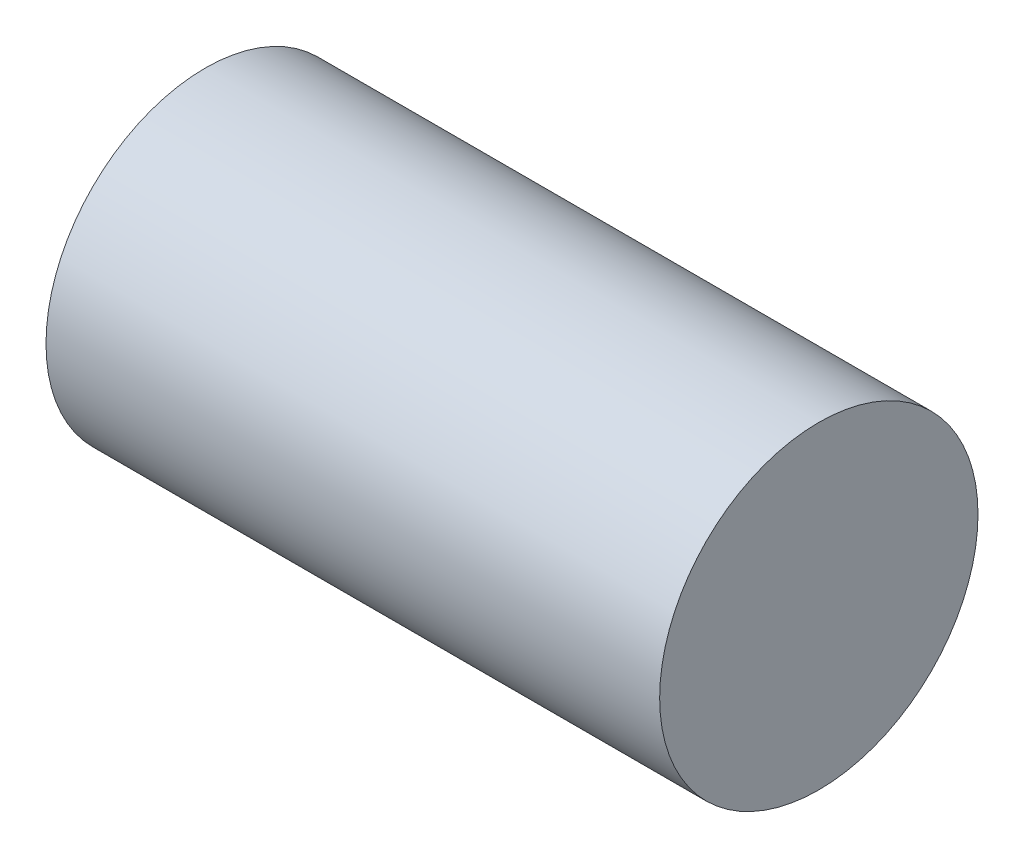
from build123d import *

# Parameters (mm, degrees)
SKETCH1_R           = 12.45
BOSS_EXTRUDE1_DEPTH = 24


with BuildPart() as part:
    # Sketch1 → Boss-Extrude1 (new body, symmetric)
    with BuildSketch(Plane(origin=(0, 0, 0), x_dir=(0, 0, -1), z_dir=(1, 0, 0))):
        Circle(SKETCH1_R)
    extrude(amount=BOSS_EXTRUDE1_DEPTH, both=True)


solid = part.part
